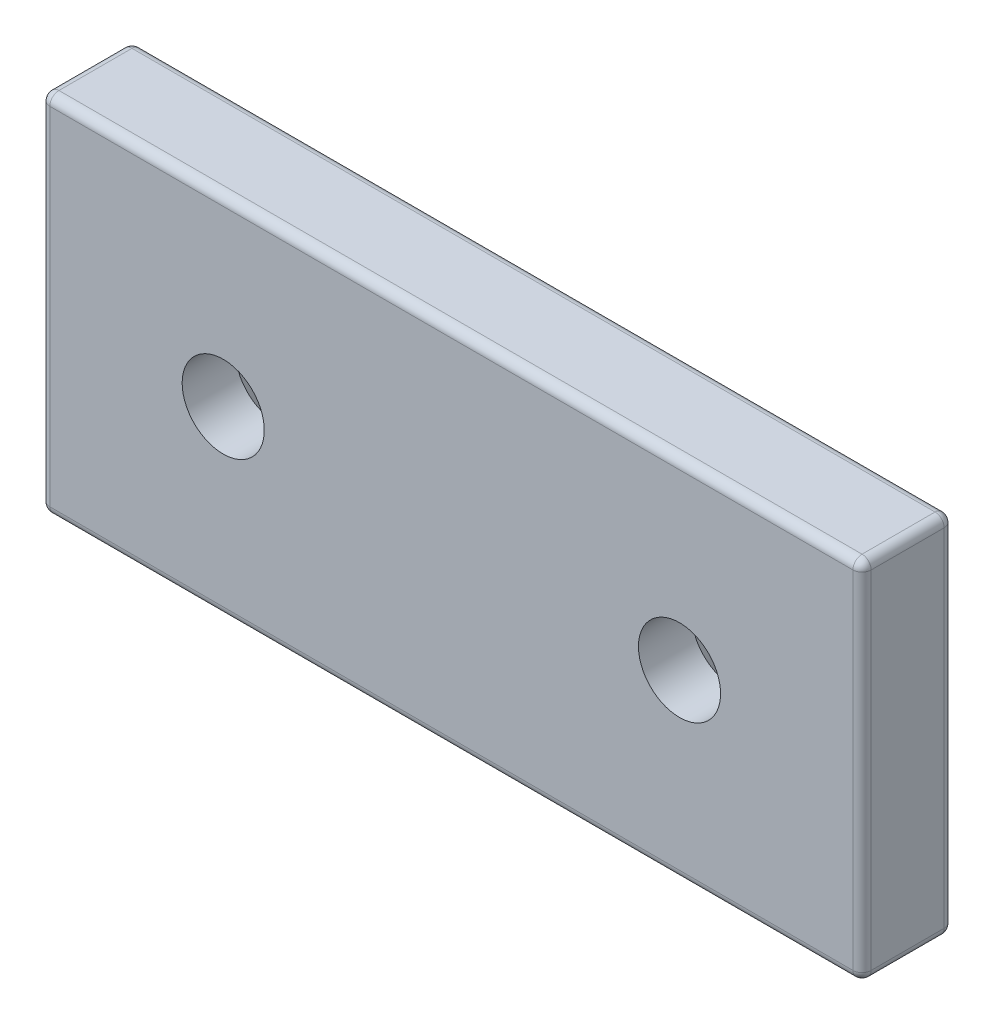
from build123d import *

# Parameters (mm, degrees)
SKETCH1_W                                       = 90
SKETCH1_H                                       = 40
BOSS_EXTRUDE1_DEPTH                             = 10
FILLET1_R                                       = 1
CSK_FOR_M8_FLAT_HEAD_MACHINE_SCREW1_D           = 9
CSK_FOR_M8_FLAT_HEAD_MACHINE_SCREW1_CSINK_D     = 17.3
CSK_FOR_M8_FLAT_HEAD_MACHINE_SCREW1_CSINK_ANGLE = 90


with BuildPart() as part:
    # Sketch1 → Boss-Extrude1 (new body)
    with BuildSketch(Plane.XY):
        Rectangle(SKETCH1_W, SKETCH1_H)
    extrude(amount=BOSS_EXTRUDE1_DEPTH)

    # Fillet1
    fillet1_edges = [part.edges().sort_by_distance(p)[0] for p in [
        (-45, 0, 10),
        (0, -20, 10),
        (45, 0, 10),
        (0, -20, 0),
        (-45, 0, 0),
        (0, 20, 0),
        (45, 0, 0),
        (0, 20, 10),
        (45, -20, 5),
        (-45, -20, 5),
        (-45, 20, 5),
        (45, 20, 5),
    ]]
    fillet(fillet1_edges, radius=FILLET1_R)

    # CSK for M8 Flat Head Machine Screw1 (through all)
    with Locations(Plane(origin=(0, 0, 0), x_dir=(-1, 0, 0), z_dir=(0, 0, -1))):
        with Locations((25, 0), (-25, 0)):
            CounterSinkHole(CSK_FOR_M8_FLAT_HEAD_MACHINE_SCREW1_D / 2, CSK_FOR_M8_FLAT_HEAD_MACHINE_SCREW1_CSINK_D / 2, counter_sink_angle=CSK_FOR_M8_FLAT_HEAD_MACHINE_SCREW1_CSINK_ANGLE)


solid = part.part
